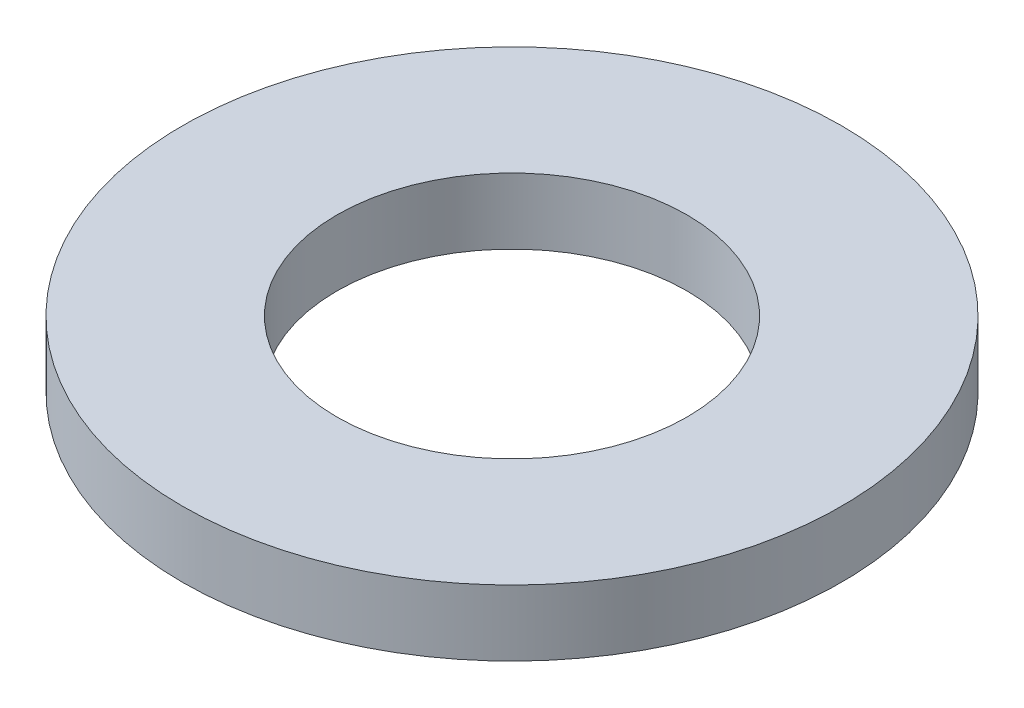
from build123d import *

# Parameters (mm, degrees)
SKETCH1_R           = 6.35
SKETCH1_R_2         = 3.3734375
BOSS_EXTRUDE1_DEPTH = 1.27


with BuildPart() as part:
    # Sketch1 → Boss-Extrude1 (new body)
    with BuildSketch(Plane(origin=(0, 0, 0), x_dir=(1, 0, 0), z_dir=(0, 1, 0))):
        Circle(SKETCH1_R)
        Circle(SKETCH1_R_2, mode=Mode.SUBTRACT)
    extrude(amount=BOSS_EXTRUDE1_DEPTH)


solid = part.part
